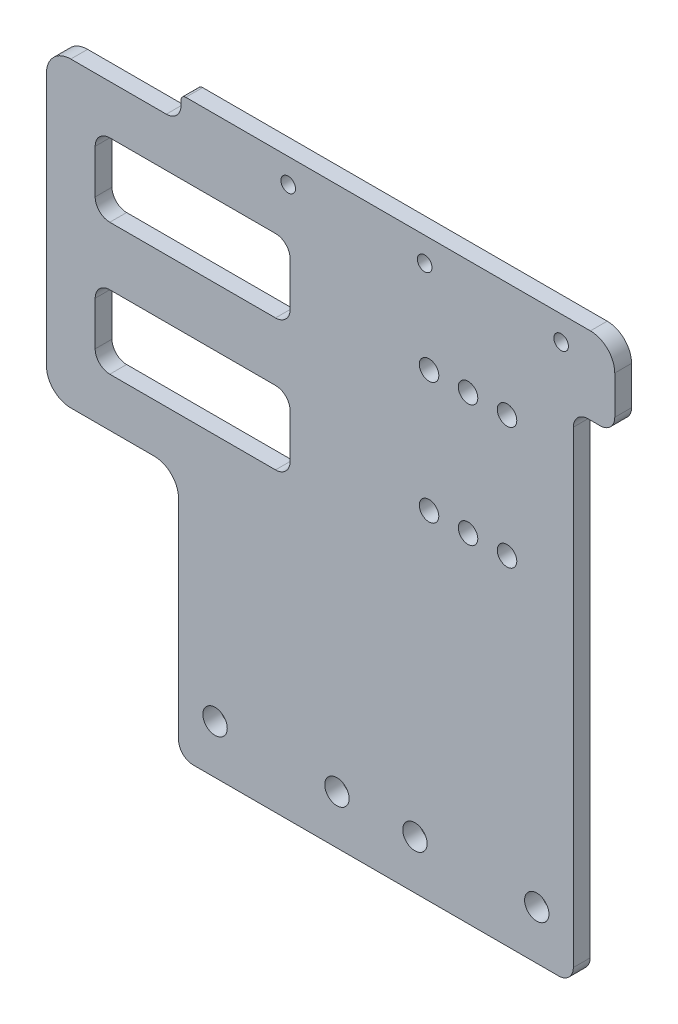
from build123d import *

# Parameters (mm, degrees)
MODEL_R         = 2.5
MODEL_R_2       = 2
MODEL_R_3       = 1.5
EXTRUDE_1_DEPTH = 3.45


with BuildPart() as part:
    # Model → 凸台-拉伸1 (new body)
    with BuildSketch(Plane.XY):
        with BuildLine():
            Line((123.577210347, 109.56127227), (123.577210347, 117.42565066))
            ThreePointArc((123.577210347, 117.42565066), (122.112744253, 120.961184566), (118.577210347, 122.42565066))
            Line((118.577210347, 122.42565066), (35.577210347, 122.42565066))
            ThreePointArc((35.577210347, 122.42565066), (34.870103566, 122.132757441), (34.577210347, 121.42565066))
            Line((34.577210347, 121.42565066), (34.577210347, 120.42565066))
            ThreePointArc((34.577210347, 120.42565066), (33.69853069, 118.304330316), (31.577210347, 117.42565066))
            Line((31.577210347, 117.42565066), (11.977210347, 117.42565066))
            ThreePointArc((11.977210347, 117.42565066), (8.441676441, 115.961184566), (6.977210347, 112.42565066))
            Line((6.977210347, 112.42565066), (6.977210347, 60.42565066))
            ThreePointArc((6.977210347, 60.42565066), (8.441676441, 56.890116754), (11.977210347, 55.42565066))
            Line((11.977210347, 55.42565066), (29.077210347, 55.42565066))
            ThreePointArc((29.077210347, 55.42565066), (32.612744253, 53.961184566), (34.077210347, 50.42565066))
            Line((34.077210347, 50.42565066), (34.077210347, 7.54555066))
            ThreePointArc((34.077210347, 7.54555066), (34.955890003, 5.424230316), (37.077210347, 4.54555066))
            Line((37.077210347, 4.54555066), (112.077210347, 4.54555066))
            ThreePointArc((112.077210347, 4.54555066), (114.19853069, 5.424230316), (115.077210347, 7.54555066))
            Line((115.077210347, 7.54555066), (115.077210347, 103.56127227))
            ThreePointArc((115.077210347, 103.56127227), (115.955890003, 105.682592613), (118.077210347, 106.56127227))
            Line((118.077210347, 106.56127227), (120.577210347, 106.56127227))
            ThreePointArc((120.577210347, 106.56127227), (122.69853069, 107.439951926), (123.577210347, 109.56127227))
        make_face()
        with Locations((82.577210347, 14.54555066)):
            Circle(MODEL_R, mode=Mode.SUBTRACT)
        with Locations((107.577210347, 14.54555066)):
            Circle(MODEL_R, mode=Mode.SUBTRACT)
        with Locations((101.477210347, 98.92565066)):
            Circle(MODEL_R_2, mode=Mode.SUBTRACT)
        with Locations((93.477210347, 98.92565066)):
            Circle(MODEL_R_2, mode=Mode.SUBTRACT)
        with Locations((85.477210347, 98.92565066)):
            Circle(MODEL_R_2, mode=Mode.SUBTRACT)
        with Locations((93.477210347, 73.92565066)):
            Circle(MODEL_R_2, mode=Mode.SUBTRACT)
        with Locations((101.477210347, 73.92565066)):
            Circle(MODEL_R_2, mode=Mode.SUBTRACT)
        with Locations((85.477210347, 73.92565066)):
            Circle(MODEL_R_2, mode=Mode.SUBTRACT)
        with Locations((84.577210347, 117.42565066)):
            Circle(MODEL_R_3, mode=Mode.SUBTRACT)
        with Locations((112.577210347, 117.42565066)):
            Circle(MODEL_R_3, mode=Mode.SUBTRACT)
        with Locations((56.577210347, 117.42565066)):
            Circle(MODEL_R_3, mode=Mode.SUBTRACT)
        with Locations((41.577210347, 14.54555066)):
            Circle(MODEL_R, mode=Mode.SUBTRACT)
        with Locations((66.577210347, 14.54555066)):
            Circle(MODEL_R, mode=Mode.SUBTRACT)
        with BuildLine():
            Line((53.977210347, 65.42565066), (19.977210347, 65.42565066))
            ThreePointArc((19.977210347, 65.42565066), (17.855890003, 66.304330316), (16.977210347, 68.42565066))
            Line((16.977210347, 68.42565066), (16.977210347, 77.42565066))
            ThreePointArc((16.977210347, 77.42565066), (17.855890003, 79.546971003), (19.977210347, 80.42565066))
            Line((19.977210347, 80.42565066), (53.977210347, 80.42565066))
            ThreePointArc((53.977210347, 80.42565066), (56.09853069, 79.546971003), (56.977210347, 77.42565066))
            Line((56.977210347, 77.42565066), (56.977210347, 68.42565066))
            ThreePointArc((56.977210347, 68.42565066), (56.09853069, 66.304330316), (53.977210347, 65.42565066))
        make_face(mode=Mode.SUBTRACT)
        with BuildLine():
            Line((53.977210347, 107.42565066), (19.977210347, 107.42565066))
            ThreePointArc((19.977210347, 107.42565066), (17.855890003, 106.546971003), (16.977210347, 104.42565066))
            Line((16.977210347, 104.42565066), (16.977210347, 95.42565066))
            ThreePointArc((16.977210347, 95.42565066), (17.855890003, 93.304330316), (19.977210347, 92.42565066))
            Line((19.977210347, 92.42565066), (53.977210347, 92.42565066))
            ThreePointArc((53.977210347, 92.42565066), (56.09853069, 93.304330316), (56.977210347, 95.42565066))
            Line((56.977210347, 95.42565066), (56.977210347, 104.42565066))
            ThreePointArc((56.977210347, 104.42565066), (56.09853069, 106.546971003), (53.977210347, 107.42565066))
        make_face(mode=Mode.SUBTRACT)
    extrude(amount=EXTRUDE_1_DEPTH)


solid = part.part
